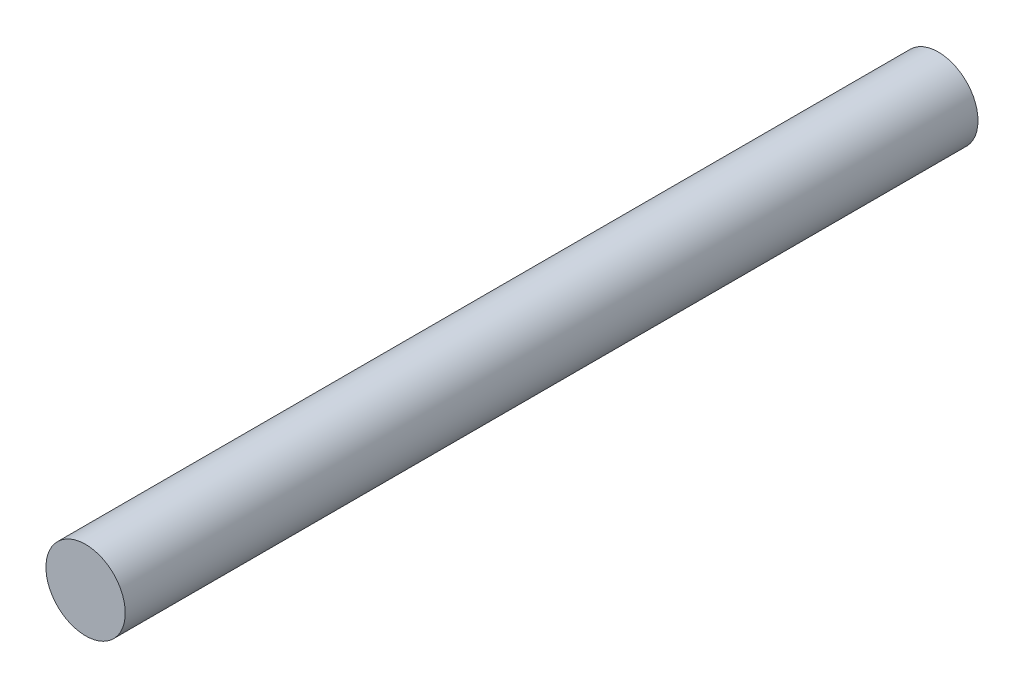
from build123d import *

# Parameters (mm, degrees)
SKETCH1_R           = 2
BOSS_EXTRUDE1_DEPTH = 43


with BuildPart() as part:
    # Sketch1 → Boss-Extrude1 (new body)
    with BuildSketch(Plane.XY):
        Circle(SKETCH1_R)
    extrude(amount=-BOSS_EXTRUDE1_DEPTH)


solid = part.part
